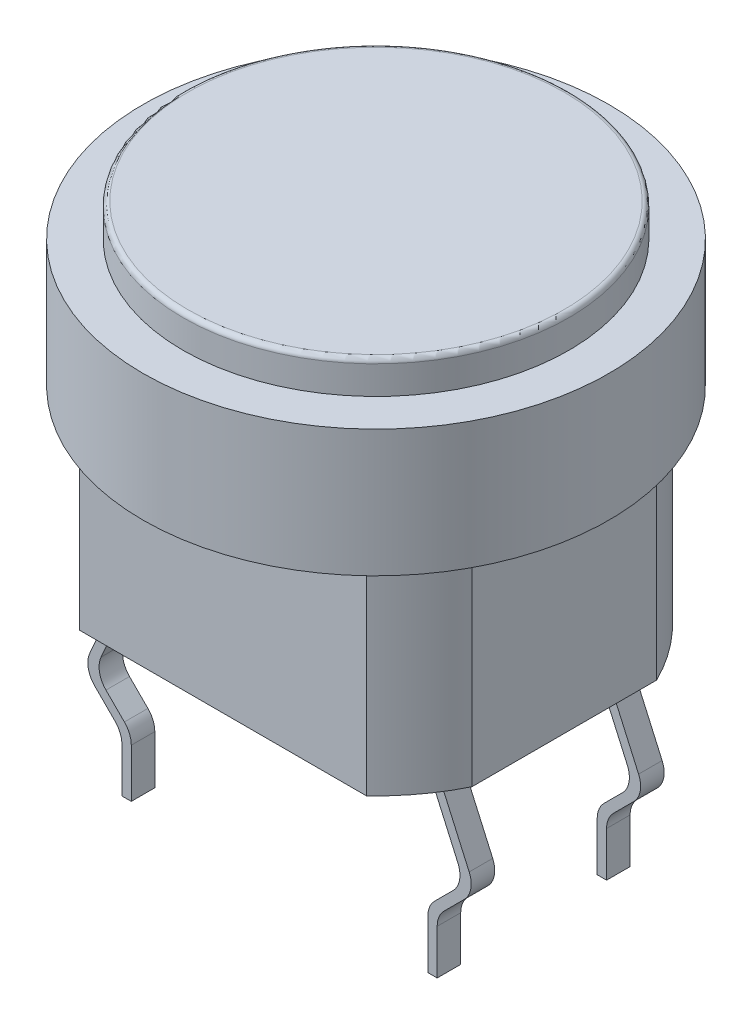
from build123d import *

# Parameters (mm, degrees)
SKETCH1_R             = 4.95
BOSS_EXTRUDE1_DEPTH   = 2.7
SKETCH2_R             = 4.1
BOSS_EXTRUDE2_DEPTH   = 0.7
BOSS_EXTRUDE3_DEPTH   = 4.4
EXTRUDE_THIN1_START   = -1.2
EXTRUDE_THIN1_DEPTH   = 0.5
EXTRUDE_THIN1_2_DEPTH = 0.5
FILLET1_R             = 0.5
FILLET2_R             = 0.5
BOSS_EXTRUDE4_REACH   = 12.458
SKETCH5_W             = 0.2
SKETCH5_H             = 0.5
BOSS_EXTRUDE5_REACH   = 12.458
SKETCH6_W             = 0.2
SKETCH6_H             = 0.5
FILLET3_R             = 0.1


with BuildPart() as part:
    # Sketch1 → Boss-Extrude1 (new body)
    with BuildSketch(Plane(origin=(0, 0, 0), x_dir=(1, 0, 0), z_dir=(0, 1, 0))):
        Circle(SKETCH1_R)
    extrude(amount=BOSS_EXTRUDE1_DEPTH)

    # Sketch2 → Boss-Extrude2 (add)
    with BuildSketch(Plane(origin=(0, 2.7, 0), x_dir=(1, 0, 0), z_dir=(0, 1, 0))):
        Circle(SKETCH2_R)
    extrude(amount=BOSS_EXTRUDE2_DEPTH)

    # Sketch3 → Boss-Extrude3 (add)
    with BuildSketch(Plane.XZ):
        with BuildLine():
            Line((3.047051854, 3.25), (-3.047051854, 3.25))
            ThreePointArc((-3.047051854, 3.25), (-3.581950323, 2.648897296), (-4, 1.96138344))
            Line((-4, 1.96138344), (-4, -1.96138344))
            ThreePointArc((-4, -1.96138344), (-3.581950323, -2.648897296), (-3.047051854, -3.25))
            Line((-3.047051854, -3.25), (3.047051854, -3.25))
            ThreePointArc((3.047051854, -3.25), (3.581950323, -2.648897296), (4, -1.96138344))
            Line((4, -1.96138344), (4, 1.96138344))
            ThreePointArc((4, 1.96138344), (3.581950323, 2.648897296), (3.047051854, 3.25))
        make_face()
    extrude(amount=BOSS_EXTRUDE3_DEPTH)

    # Boss-Extrude4: up to this face of the body (flat: up to its plane)
    boss_extrude4_end = Plane(part.part.faces().sort_by_distance((0, -4.4, 0))[0])
    # Sketch5 → Boss-Extrude4 (add, up to the picked face)
    with BuildSketch(Plane(origin=(2.169072165, -4.880412371, 0), x_dir=(0.913811549, 0.406138466, 0), z_dir=(-0.406138466, 0.913811549, 0)), mode=Mode.PRIVATE) as boss_extrude4_sk1:
        with Locations((1.182878282, -1.8)):
            Rectangle(SKETCH5_W, SKETCH5_H)
    boss_extrude4_tool1 = split(extrude(boss_extrude4_sk1.sketch, amount=BOSS_EXTRUDE4_REACH, mode=Mode.PRIVATE), bisect_by=boss_extrude4_end, keep=Keep.BOTH, mode=Mode.PRIVATE)
    add(boss_extrude4_tool1.solids().sort_by_distance((3.25, -4.4, 1.8))[0])

    # Boss-Extrude5: up to this face of the body (flat: up to its plane)
    boss_extrude5_end = Plane(part.part.faces().sort_by_distance((-0.003510671, -4.4, -0.001977667))[0])
    # Sketch6 → Boss-Extrude5 (add, up to the picked face)
    with BuildSketch(Plane(origin=(-2.169072165, -4.880412371, 0), x_dir=(0.913811549, -0.406138466, 0), z_dir=(0.406138466, 0.913811549, 0)), mode=Mode.PRIVATE) as boss_extrude5_sk1:
        with Locations((-1.182878282, -1.8)):
            Rectangle(SKETCH6_W, SKETCH6_H)
    boss_extrude5_tool1 = split(extrude(boss_extrude5_sk1.sketch, amount=BOSS_EXTRUDE5_REACH, mode=Mode.PRIVATE), bisect_by=boss_extrude5_end, keep=Keep.BOTH, mode=Mode.PRIVATE)
    add(boss_extrude5_tool1.solids().sort_by_distance((-3.25, -4.4, 1.8))[0])

    # Fillet3
    fillet3_edges = [part.edges().sort_by_distance(p)[0] for p in [
        (-4.1, 3.4, 0),
    ]]
    fillet(fillet3_edges, radius=FILLET3_R)


with BuildPart() as body_2:
    # Sketch4 → Extrude-Thin1 (new body)
    with BuildSketch(Plane.XY.offset(3.25).offset(EXTRUDE_THIN1_START)):
        Polygon((-3.341381155, -4.359386153), (-4.169274708, -6.222146648), (-3.35, -7.041421356), (-3.35, -8.2), (-3.15, -8.2), (-3.15, -6.958578644), (-3.930725292, -6.177853352), (-3.158618845, -4.440613847), align=None)
    extrude(amount=-EXTRUDE_THIN1_DEPTH)

    # Fillet1
    fillet1_edges = [body_2.edges().sort_by_distance(p)[0] for p in [
        (-3.35, -7.041421356, 1.8),
        (-4.169274708, -6.222146648, 1.8),
        (-3.930725292, -6.177853352, 1.8),
        (-3.15, -6.958578644, 1.8),
    ]]
    fillet(fillet1_edges, radius=FILLET1_R)


with BuildPart() as body_3:
    # Sketch4 → Extrude-Thin1 2 (new body)
    with BuildSketch(Plane.XY.offset(3.25).offset(EXTRUDE_THIN1_START)):
        Polygon((3.158618845, -4.440613847), (3.930725292, -6.177853352), (3.15, -6.958578644), (3.15, -8.2), (3.35, -8.2), (3.35, -7.041421356), (4.169274708, -6.222146648), (3.341381155, -4.359386153), align=None)
    extrude(amount=-EXTRUDE_THIN1_2_DEPTH)

    # Fillet2
    fillet2_edges = [body_3.edges().sort_by_distance(p)[0] for p in [
        (3.15, -6.958578644, 1.8),
        (3.930725292, -6.177853352, 1.8),
        (4.169274708, -6.222146648, 1.8),
        (3.35, -7.041421356, 1.8),
    ]]
    fillet(fillet2_edges, radius=FILLET2_R)


with BuildPart() as body_4:
    # Mirror2: mirrored copy
    add(body_2.part.mirror(Plane.XY))


with BuildPart() as body_5:
    # Mirror2 2: mirrored copy
    add(body_3.part.mirror(Plane.XY))


solid = Compound([part.part, body_2.part, body_3.part, body_4.part, body_5.part])
